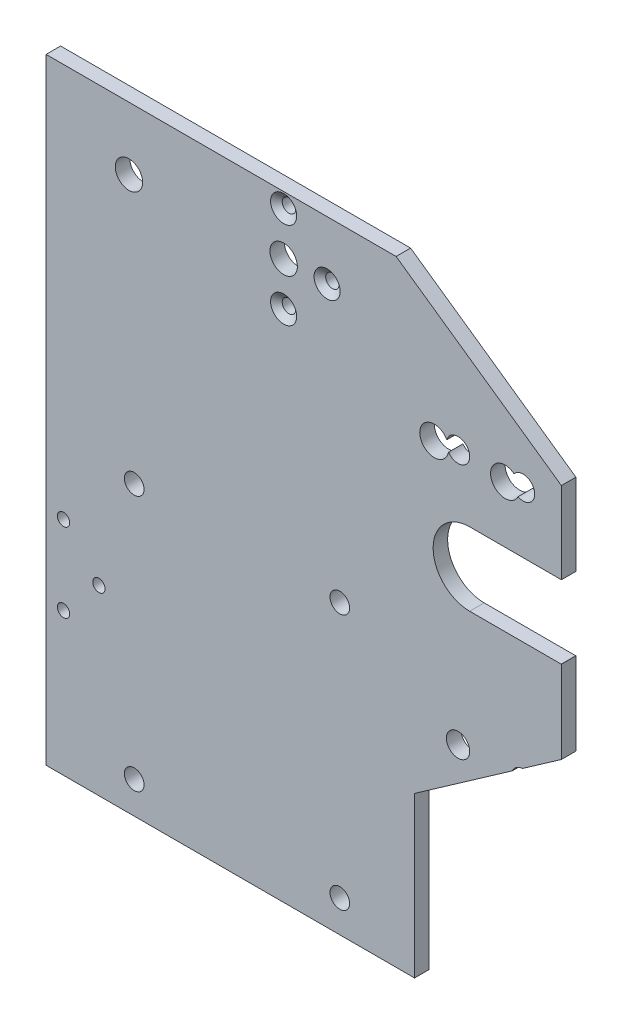
from build123d import *

# Parameters (mm, degrees)
BOSS_EXTRUDE1_DEPTH                               = 99.75
BOSS_EXTRUDE1_DEPTH_BACK                          = 35
SKETCH1_W                                         = 112.782
SKETCH1_H                                         = 3.175
CUT_EXTRUDE1_DEPTH                                = 129.830795468
CUT_EXTRUDE1_DEPTH_BACK                           = 129.830795468
SKETCH2_R                                         = 3.175
M4_CLEARANCE_HOLE1_D                              = 4.3
CSK_FOR_4_FLAT_HEAD_MACHINE_SCREW_100_D           = 2.9464
CSK_FOR_4_FLAT_HEAD_MACHINE_SCREW_100_CSINK_D     = 5.715
CSK_FOR_4_FLAT_HEAD_MACHINE_SCREW_100_CSINK_ANGLE = 100
SKETCH8_R                                         = 3
CUT_EXTRUDE3_DEPTH                                = 3.5
F_6_32_TAPPED_HOLE1_D                             = 2.7051
F_1_4_20_TAPPED_HOLE1_D                           = 5.1054
SKETCH16_R                                        = 2.9972
CUT_EXTRUDE4_DEPTH                                = 128.996890044


with BuildPart() as part:
    # Sketch1 → Boss-Extrude1 (new, two sides: drawn at the far end of the back side and taken through both)
    with BuildSketch(Plane(origin=(0, 0, 0), x_dir=(1, 0, 0), z_dir=(0, 1, 0)).offset(-BOSS_EXTRUDE1_DEPTH_BACK)):
        with Locations((23.753, -13.3875)):
            Rectangle(SKETCH1_W, SKETCH1_H)
    extrude(amount=BOSS_EXTRUDE1_DEPTH + BOSS_EXTRUDE1_DEPTH_BACK)

    # Sketch2 → Cut-Extrude1 (cut, two sides: drawn at the far end of the back side and taken through both)
    with BuildSketch(Plane.XY.offset(-CUT_EXTRUDE1_DEPTH_BACK)):
        with Locations((67.816, 68.973813735)):
            Circle(SKETCH2_R)
        with Locations((52.316, 68.973813735)):
            Circle(SKETCH2_R)
        Polygon((48, -35), (80.144, -35), (80.144, 22.487287802), (48, -0.020183306), align=None)
        with BuildLine():
            Line((60.066, 56.550419976), (80.066, 56.550419976))
            ThreePointArc((80.066, 56.550419976), (88.066, 48.550419976), (80.066, 40.550419976))
            Line((80.066, 40.550419976), (60.066, 40.550419976))
            ThreePointArc((60.066, 40.550419976), (52.066, 48.550419976), (60.066, 56.550419976))
        make_face()
        Polygon((43.964687276, 99.75), (80.144, 74.416972504), (80.144, 99.75), align=None)
    extrude(amount=CUT_EXTRUDE1_DEPTH + CUT_EXTRUDE1_DEPTH_BACK, mode=Mode.SUBTRACT)

    # M4 Clearance Hole1 (through all)
    with Locations(Plane.XY.offset(14.975)):
        with Locations((-13.356, 28), (31.644, 28), (31.644, -28), (-13.356, -28)):
            Hole(M4_CLEARANCE_HOLE1_D / 2)

    # CSK for _4 Flat Head Machine Screw _100 (through all)
    with Locations(Plane.XY.offset(14.975)):
        with Locations((19.352, 96.519071488), (28.871071488, 87), (19.352, 77.480928512)):
            CounterSinkHole(CSK_FOR_4_FLAT_HEAD_MACHINE_SCREW_100_D / 2, CSK_FOR_4_FLAT_HEAD_MACHINE_SCREW_100_CSINK_D / 2, counter_sink_angle=CSK_FOR_4_FLAT_HEAD_MACHINE_SCREW_100_CSINK_ANGLE)

    # Sketch8 → Cut-Extrude3 (cut)
    with BuildSketch(Plane.XY.offset(14.975)):
        with Locations((19.352, 87)):
            Circle(SKETCH8_R)
    extrude(amount=-CUT_EXTRUDE3_DEPTH, mode=Mode.SUBTRACT)

    # 6-32 Tapped Hole1 (through all)
    with Locations(Plane.XY.offset(14.975)):
        with Locations((-28.824, -3.758), (-21.077, 4.878), (-28.824, 13.514)):
            Hole(F_6_32_TAPPED_HOLE1_D / 2)

    # 1_4-20 Tapped Hole1 (through all)
    with Locations(Plane.XY.offset(14.975)):
        with Locations((57.526, 13.97), (71.75, 13.97), (71.75, 69.85), (57.526, 69.85)):
            Hole(F_1_4_20_TAPPED_HOLE1_D / 2)

    # Sketch16 → Cut-Extrude4 (cut, through all)
    with BuildSketch(Plane.XY.offset(14.975)):
        with Locations((-14.5061, 86.034)):
            Circle(SKETCH16_R)
    extrude(amount=-CUT_EXTRUDE4_DEPTH, mode=Mode.SUBTRACT)


solid = part.part
